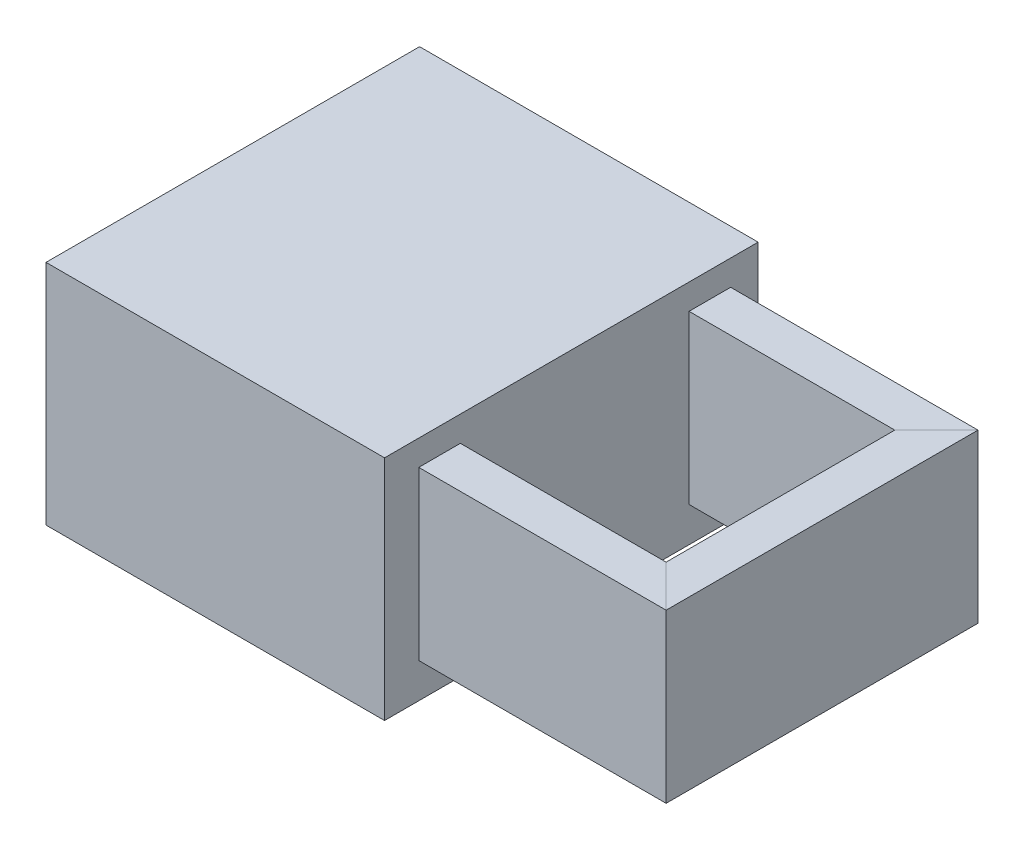
from build123d import *

# Parameters (mm, degrees)
SKETCH1_W           = 81.56143141
SKETCH1_H           = 54.816869018
BOSS_EXTRUDE1_DEPTH = 90
SKETCH2_W           = 10.019793311
SKETCH2_H           = 40.301038966


with BuildPart() as part:
    # Sketch1 → Boss-Extrude1 (new body)
    with BuildSketch(Plane(origin=(-20.318735881, -25.313413314, 0), x_dir=(1, 0, 0), z_dir=(0, 0, 1))):
        with Locations((14.605186555, -6.069687919)):
            Rectangle(SKETCH1_W, SKETCH1_H)
    extrude(amount=BOSS_EXTRUDE1_DEPTH)

    # Sweep3: sweep along a path in Sketch3
    with BuildLine(Plane(origin=(0, -10.087901928, 0), x_dir=(1, 0, 0), z_dir=(0, 1, 0))) as sweep3_path:
        Line((35.067166378, -76.74628409), (89.647981196, -76.74628409))
        Line((89.647981196, -76.74628409), (89.647981196, -11.63207723))
        Line((89.647981196, -11.63207723), (35.067166378, -11.63207723))
    # Sketch2 → Sweep3 (sweep)
    with BuildSketch(Plane(origin=(35.067166378, 0, 0), x_dir=(0, 0, -1), z_dir=(1, 0, 0))):
        with Locations((-76.74628409, -30.238421411)):
            Rectangle(SKETCH2_W, SKETCH2_H)
    sweep(path=sweep3_path.line, transition=Transition.RIGHT)


solid = part.part
